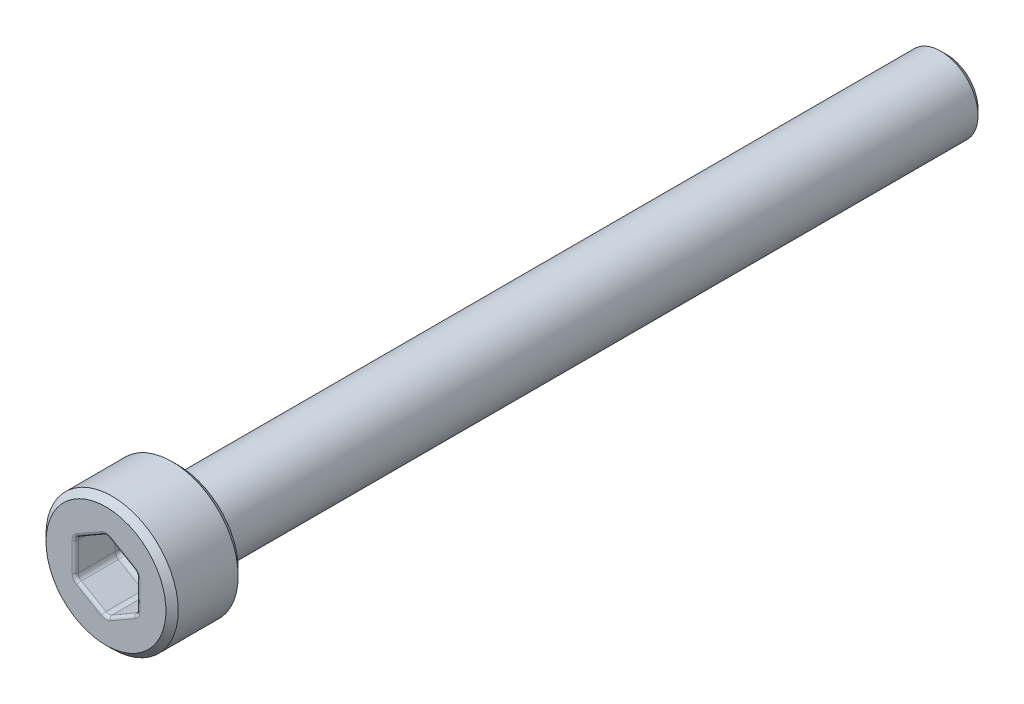
from build123d import *

# Parameters (mm, degrees)
SCHNITT_LINEAR_AUSTRAGEN1_DEPTH = 1.5
FASE1_SIZE                      = 0.2
VERRUNDUNG1_R                   = 0.2
VERRUNDUNG2_R                   = 0.1


with BuildPart() as part:
    # Skizze1 → Rotation1 (revolve)
    with BuildSketch(Plane(origin=(0, 0, 0), x_dir=(0, 0, -1), z_dir=(1, 0, 0))):
        Polygon((-2.35, 0), (-2.35, 2.15), (0, 2.15), (0, 1.21), (25, 1.21), (25, 0), align=None)
    revolve(axis=Axis((0, 0, 21.919879518), (0, 0, -1)))

    # Skizze2 → Schnitt-Linear austragen1 (cut)
    with BuildSketch(Plane.XY.offset(2.35)):
        Polygon((1, -0.577350269), (1, 0.577350269), (0, 1.154700538), (-1, 0.577350269), (-1, -0.577350269), (0, -1.154700538), align=None)
    extrude(amount=-SCHNITT_LINEAR_AUSTRAGEN1_DEPTH, mode=Mode.SUBTRACT)

    # Fase1
    fase1_edges = [part.edges().sort_by_distance(p)[0] for p in [
        (0, -1.21, -25),
        (0, -2.15, 0),
        (0, -2.15, 2.35),
    ]]
    chamfer(fase1_edges, length=FASE1_SIZE)

    # Verrundung1
    verrundung1_edges = [part.edges().sort_by_distance(p)[0] for p in [
        (0.5, -0.866025404, 0.85),
        (1, -0.577350269, 1.6),
        (-0.5, -0.866025404, 0.85),
        (0, -1.154700538, 1.6),
        (-1, 0, 0.85),
        (-1, -0.577350269, 1.6),
        (-0.5, 0.866025404, 0.85),
        (-1, 0.577350269, 1.6),
        (0.5, 0.866025404, 0.85),
        (0, 1.154700538, 1.6),
        (1, 0, 0.85),
        (1, 0.577350269, 1.6),
        (0, -1.21, 0),
    ]]
    fillet(verrundung1_edges, radius=VERRUNDUNG1_R)

    # Verrundung2
    verrundung2_edges = [part.edges().sort_by_distance(p)[0] for p in [
        (-0.5, -0.866025404, 2.35),
        (-1, 0, 2.35),
        (-0.5, 0.866025404, 2.35),
        (0.5, 0.866025404, 2.35),
        (1, 0, 2.35),
        (0.5, -0.866025404, 2.35),
        (-0.973205081, -0.561880215, 2.35),
        (0, -1.123760431, 2.35),
        (0.973205081, -0.561880215, 2.35),
        (0.973205081, 0.561880215, 2.35),
        (0, 1.123760431, 2.35),
        (-0.973205081, 0.561880215, 2.35),
    ]]
    fillet(verrundung2_edges, radius=VERRUNDUNG2_R)


solid = part.part
